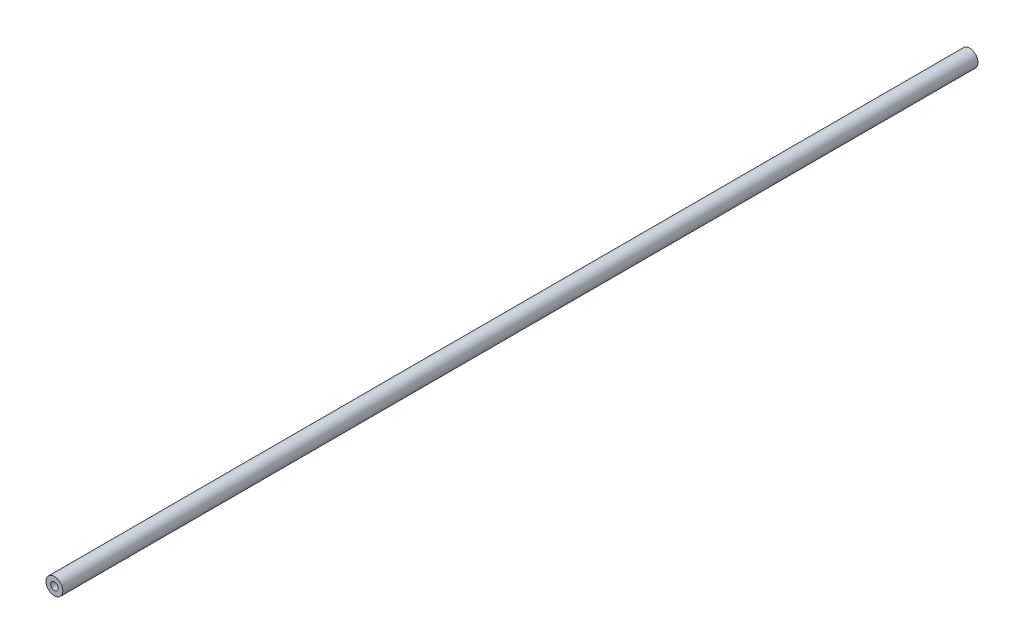
from build123d import *

# Parameters (mm, degrees)
SKETCH_1_R      = 4.5
SKETCH_1_R_2    = 2
EXTRUDE_1_DEPTH = 490


with BuildPart() as part:
    # 草图1 → 凸台-拉伸1 (new body)
    with BuildSketch(Plane.XY):
        Circle(SKETCH_1_R)
        Circle(SKETCH_1_R_2, mode=Mode.SUBTRACT)
    extrude(amount=EXTRUDE_1_DEPTH)


solid = part.part
